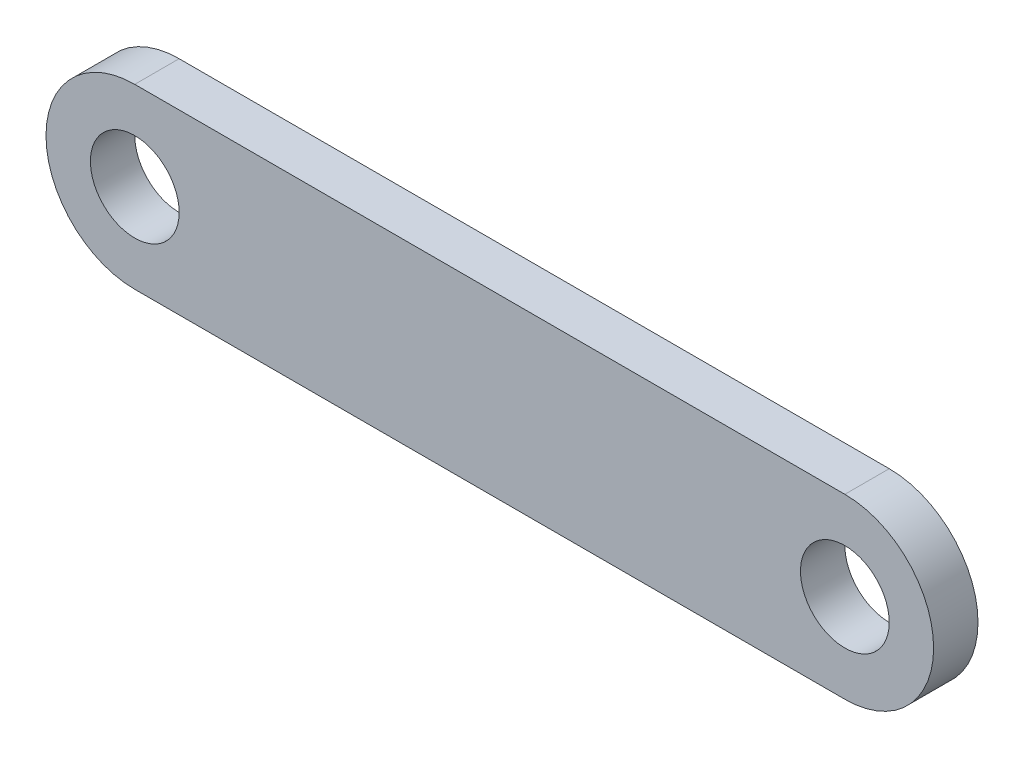
from build123d import *

# Parameters (mm, degrees)
SKETCH1_R           = 3.175
BOSS_EXTRUDE1_DEPTH = 3.175


with BuildPart() as part:
    # Sketch1 → Boss-Extrude1 (new body)
    with BuildSketch(Plane.XY):
        with BuildLine():
            Line((0, 6.35), (50.8, 6.35))
            ThreePointArc((50.8, 6.35), (57.15, 0), (50.8, -6.35))
            Line((50.8, -6.35), (0, -6.35))
            ThreePointArc((0, -6.35), (-6.35, 0), (0, 6.35))
        make_face()
        Circle(SKETCH1_R, mode=Mode.SUBTRACT)
        with Locations((50.8, 0)):
            Circle(SKETCH1_R, mode=Mode.SUBTRACT)
    extrude(amount=BOSS_EXTRUDE1_DEPTH)


solid = part.part
